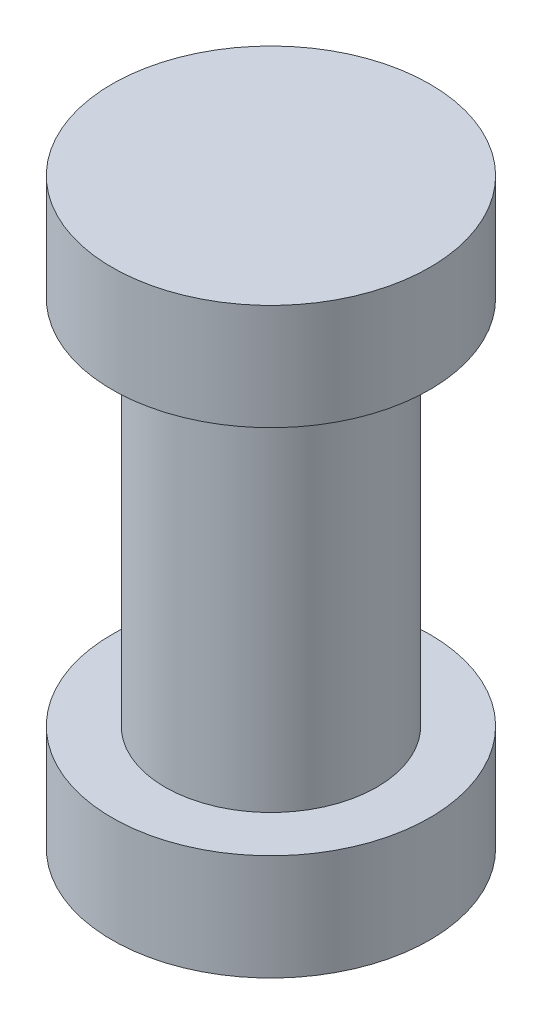
from build123d import *


with BuildPart() as part:
    # 草图1 → 旋转1 (revolve)
    with BuildSketch(Plane.XY):
        Polygon((0, 2.651785714), (1.5, 2.651785714), (1.5, 1.651785714), (1, 1.651785714), (1, -1.848214286), (1.5, -1.848214286), (1.5, -2.848214286), (0, -2.848214286), align=None)
    revolve(axis=Axis((0, -2.848214286, 0), (0, 1, 0)))


solid = part.part
